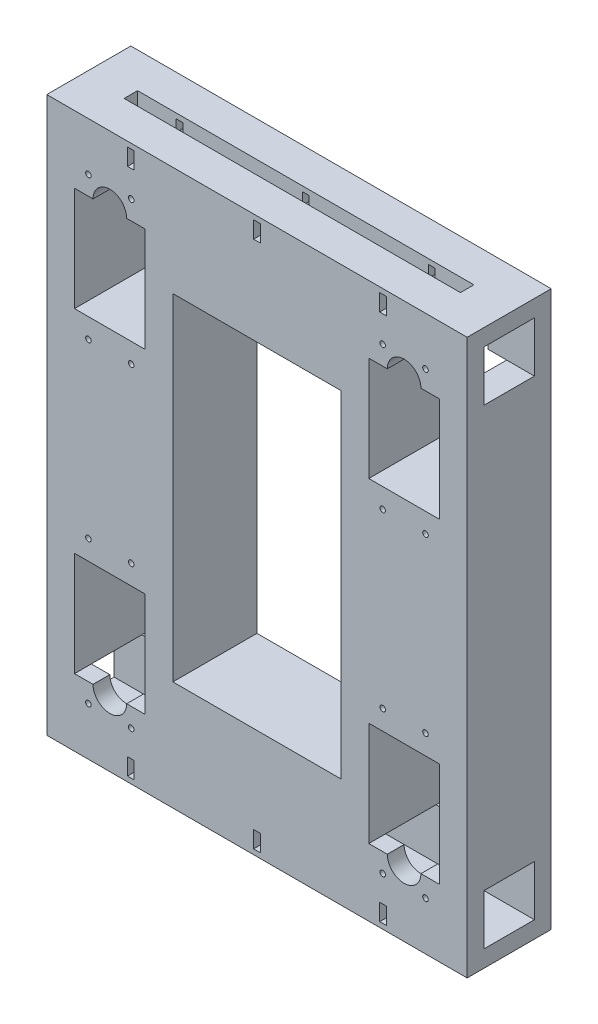
from build123d import *

# Parameters (mm, degrees)
CROQUIS1_W                                     = 250
CROQUIS1_H                                     = 250
CROQUIS1_W_2                                   = 100
CROQUIS1_H_2                                   = 200
SALIENTE_EXTRUIR1_DEPTH                        = 50
SALIENTE_EXTRUIR2_DEPTH                        = 250
CROQUIS5_W                                     = 200
CROQUIS5_H                                     = 8
CORTAR_EXTRUIR1_DEPTH                          = 10
CORTAR_EXTRUIR3_DEPTH                          = 51
CORTAR_EXTRUIR5_DEPTH                          = 51
PERFORADOR_PARA_ROSCAR_PARA_MACHO_DE_2_COUNT   = 2
PERFORADOR_PARA_ROSCAR_PARA_MACHO_DE_2_PITCH   = 25.455844123
PERFORADOR_PARA_ROSCAR_PARA_MACHO_DE_3_COUNT   = 2
PERFORADOR_PARA_ROSCAR_PARA_MACHO_DE_3_PITCH   = 88.729927308
PERFORADOR_PARA_ROSCAR_PARA_MACHO_DE_4_COUNT   = 2
PERFORADOR_PARA_ROSCAR_PARA_MACHO_DE_4_PITCH   = 85
PERFORADOR_PARA_ROSCAR_PARA_MACHO_DE_5_COUNT   = 2
PERFORADOR_PARA_ROSCAR_PARA_MACHO_DE_5_PITCH   = 175
PERFORADOR_PARA_ROSCAR_PARA_MACHO_DE_6_COUNT   = 2
PERFORADOR_PARA_ROSCAR_PARA_MACHO_DE_6_PITCH   = 149.544155877
PERFORADOR_PARA_ROSCAR_PARA_MACHO_DE_7_COUNT   = 2
PERFORADOR_PARA_ROSCAR_PARA_MACHO_DE_7_PITCH   = 194.550764583
PERFORADOR_PARA_ROSCAR_PARA_MACHO_DE_8_COUNT   = 2
PERFORADOR_PARA_ROSCAR_PARA_MACHO_DE_8_PITCH   = 172.012948806
PERFORADOR_PARA_ROSCAR_PARA_MACHO_DE_9_A_COUNT = 2
PERFORADOR_PARA_ROSCAR_PARA_MACHO_DE_9_A_PITCH = 25.455844123
PERFORADOR_PARA_ROSCAR_PARA_MACHO_DE_10_COUNT  = 2
PERFORADOR_PARA_ROSCAR_PARA_MACHO_DE_10_PITCH  = 88.729927308
PERFORADOR_PARA_ROSCAR_PARA_MACHO_DE_11_COUNT  = 2
PERFORADOR_PARA_ROSCAR_PARA_MACHO_DE_11_PITCH  = 85
PERFORADOR_PARA_ROSCAR_PARA_MACHO_DE_12_COUNT  = 2
PERFORADOR_PARA_ROSCAR_PARA_MACHO_DE_12_PITCH  = 194.550764583
PERFORADOR_PARA_ROSCAR_PARA_MACHO_DE_13_COUNT  = 2
PERFORADOR_PARA_ROSCAR_PARA_MACHO_DE_13_PITCH  = 172.012948806
PERFORADOR_PARA_ROSCAR_PARA_MACHO_DE_14_COUNT  = 2
PERFORADOR_PARA_ROSCAR_PARA_MACHO_DE_14_PITCH  = 149.544155877
PERFORADOR_PARA_ROSCAR_PARA_MACHO_DE_15_COUNT  = 2
PERFORADOR_PARA_ROSCAR_PARA_MACHO_DE_15_PITCH  = 175
SALIENTE_EXTRUIR4_DEPTH                        = 50
CROQUIS15_W                                    = 200
CROQUIS15_H                                    = 8
CORTAR_EXTRUIR6_DEPTH                          = 30
CROQUIS16_W                                    = 30
CROQUIS16_H                                    = 30
CORTAR_EXTRUIR7_DEPTH                          = 251
CROQUIS17_R                                    = 1.5
CORTAR_EXTRUIR8_DEPTH                          = 2
SIMETR_A6_COPY_1_SKETCH_R                      = 1.5
SIMETR_A6_COPY_1_DEPTH                         = 2


with BuildPart() as part:
    # Croquis1 → Saliente-Extruir1 (new body)
    with BuildSketch(Plane.XY):
        with Locations((125, 125)):
            Rectangle(CROQUIS1_W, CROQUIS1_H)
        with Locations((125, 125)):
            Rectangle(CROQUIS1_W_2, CROQUIS1_H_2, mode=Mode.SUBTRACT)
    extrude(amount=SALIENTE_EXTRUIR1_DEPTH)

    # Croquis4 → Saliente-Extruir2 (add, through all)
    with BuildSketch(Plane(origin=(250, 0, 0), x_dir=(0, 0, -1), z_dir=(1, 0, 0))):
        Polygon((-10, 280), (-10, 250), (0, 250), (0, 290), (-50, 290), (-50, 250), (-40, 250), (-40, 280), (-25, 280), align=None)
        Polygon((0, 0), (0, -40), (-50, -40), (-50, 0), (-40, 0), (-40, -30), (-25, -30), (-10, -30), (-10, 0), align=None)
    extrude(amount=-SALIENTE_EXTRUIR2_DEPTH)

    # Croquis5 → Cortar-Extruir1 (cut)
    with BuildSketch(Plane(origin=(0, 290, 0), x_dir=(1, 0, 0), z_dir=(0, 1, 0))):
        with Locations((125, -25)):
            Rectangle(CROQUIS5_W, CROQUIS5_H)
    cortar_extruir1 = extrude(amount=-CORTAR_EXTRUIR1_DEPTH, mode=Mode.SUBTRACT)

    # Croquis7 → Cortar-Extruir3 (cut, through all)
    with BuildSketch(Plane.XY.offset(50)):
        with BuildLine():
            Line((198, 287), (198, 277))
            ThreePointArc((198, 277), (200, 275), (202, 277))
            Line((202, 277), (202, 287))
            ThreePointArc((202, 287), (200, 289), (198, 287))
        make_face()
        with BuildLine():
            Line((127, 287), (127, 277))
            ThreePointArc((127, 277), (125, 275), (123, 277))
            Line((123, 277), (123, 287))
            ThreePointArc((123, 287), (125, 289), (127, 287))
        make_face()
        with BuildLine():
            Line((48, 287), (48, 277))
            ThreePointArc((48, 277), (50, 275), (52, 277))
            Line((52, 277), (52, 287))
            ThreePointArc((52, 287), (50, 289), (48, 287))
        make_face()
    cortar_extruir3 = extrude(amount=-CORTAR_EXTRUIR3_DEPTH, mode=Mode.SUBTRACT)

    # Croquis8 → Cortar-Extruir5 (cut, through all)
    with BuildSketch(Plane.XY.offset(50)):
        with BuildLine():
            Line((27.5, 250), (16.5, 250))
            Line((16.5, 250), (16.5, 188))
            Line((16.5, 188), (58.5, 188))
            Line((58.5, 188), (58.5, 250))
            Line((58.5, 250), (47.5, 250))
            ThreePointArc((47.5, 250), (37.5, 260), (27.5, 250))
        make_face()
        with BuildLine():
            Line((191.5, 250), (202.5, 250))
            ThreePointArc((202.5, 250), (212.5, 260), (222.5, 250))
            Line((222.5, 250), (233.5, 250))
            Line((233.5, 250), (233.5, 188))
            Line((233.5, 188), (191.5, 188))
            Line((191.5, 188), (191.5, 250))
        make_face()
    cortar_extruir5 = extrude(amount=-CORTAR_EXTRUIR5_DEPTH, mode=Mode.SUBTRACT)

    # Croquis11 → Perforador para roscar para macho de ros (revolve, cut)
    with BuildSketch(Plane(origin=(50.227922061, 261.272077939, 50), x_dir=(0, -1, 0), z_dir=(1, 0, 0))):
        Polygon((0, 0), (0, 10.991420021), (1.65, 10), (1.65, 0), align=None)
    perforador_para_roscar_para_macho_de_ros = revolve(axis=Axis((50.227922061, 261.272077939, 56.35), (0, 0, -1)), mode=Mode.SUBTRACT)

    # Perforador para roscar para macho de 2: Perforador para roscar para macho de ros ×2
    with Locations(*[(-i * PERFORADOR_PARA_ROSCAR_PARA_MACHO_DE_2_PITCH, 0, 0) for i in range(1, PERFORADOR_PARA_ROSCAR_PARA_MACHO_DE_2_COUNT)]):
        add(perforador_para_roscar_para_macho_de_ros, mode=Mode.SUBTRACT)

    # Perforador para roscar para macho de 3: Perforador para roscar para macho de ros ×2
    with Locations(*[Vector(-0.286891299, -0.957963143, 0) * (i * PERFORADOR_PARA_ROSCAR_PARA_MACHO_DE_3_PITCH) for i in range(1, PERFORADOR_PARA_ROSCAR_PARA_MACHO_DE_3_COUNT)]):
        add(perforador_para_roscar_para_macho_de_ros, mode=Mode.SUBTRACT)

    # Perforador para roscar para macho de 4: Perforador para roscar para macho de ros ×2
    with Locations(*[(0, -i * PERFORADOR_PARA_ROSCAR_PARA_MACHO_DE_4_PITCH, 0) for i in range(1, PERFORADOR_PARA_ROSCAR_PARA_MACHO_DE_4_COUNT)]):
        add(perforador_para_roscar_para_macho_de_ros, mode=Mode.SUBTRACT)

    # Perforador para roscar para macho de 5: Perforador para roscar para macho de ros ×2
    with Locations(*[(i * PERFORADOR_PARA_ROSCAR_PARA_MACHO_DE_5_PITCH, 0, 0) for i in range(1, PERFORADOR_PARA_ROSCAR_PARA_MACHO_DE_5_COUNT)]):
        add(perforador_para_roscar_para_macho_de_ros, mode=Mode.SUBTRACT)

    # Perforador para roscar para macho de 6: Perforador para roscar para macho de ros ×2
    with Locations(*[(i * PERFORADOR_PARA_ROSCAR_PARA_MACHO_DE_6_PITCH, 0, 0) for i in range(1, PERFORADOR_PARA_ROSCAR_PARA_MACHO_DE_6_COUNT)]):
        add(perforador_para_roscar_para_macho_de_ros, mode=Mode.SUBTRACT)

    # Perforador para roscar para macho de 7: Perforador para roscar para macho de ros ×2
    with Locations(*[Vector(0.899508159, -0.436903963, 0) * (i * PERFORADOR_PARA_ROSCAR_PARA_MACHO_DE_7_PITCH) for i in range(1, PERFORADOR_PARA_ROSCAR_PARA_MACHO_DE_7_COUNT)]):
        add(perforador_para_roscar_para_macho_de_ros, mode=Mode.SUBTRACT)

    # Perforador para roscar para macho de 8: Perforador para roscar para macho de ros ×2
    with Locations(*[Vector(0.869377317, -0.494148845, 0) * (i * PERFORADOR_PARA_ROSCAR_PARA_MACHO_DE_8_PITCH) for i in range(1, PERFORADOR_PARA_ROSCAR_PARA_MACHO_DE_8_COUNT)]):
        add(perforador_para_roscar_para_macho_de_ros, mode=Mode.SUBTRACT)

    # Croquis13 → Perforador para roscar para macho de 9 (revolve, cut)
    with BuildSketch(Plane(origin=(50.227922061, 261.272077939, 0), x_dir=(0, 1, 0), z_dir=(1, 0, 0))):
        Polygon((0, 0), (0, 10.991420021), (1.65, 10), (1.65, 0), align=None)
    perforador_para_roscar_para_macho_de_9 = revolve(axis=Axis((50.227922061, 261.272077939, -6.35), (0, 0, 1)), mode=Mode.SUBTRACT)

    # Perforador para roscar para macho de 9 a: Perforador para roscar para macho de 9 ×2
    with Locations(*[(-i * PERFORADOR_PARA_ROSCAR_PARA_MACHO_DE_9_A_PITCH, 0, 0) for i in range(1, PERFORADOR_PARA_ROSCAR_PARA_MACHO_DE_9_A_COUNT)]):
        add(perforador_para_roscar_para_macho_de_9, mode=Mode.SUBTRACT)

    # Perforador para roscar para macho de 10: Perforador para roscar para macho de 9 ×2
    with Locations(*[Vector(-0.286891299, -0.957963143, 0) * (i * PERFORADOR_PARA_ROSCAR_PARA_MACHO_DE_10_PITCH) for i in range(1, PERFORADOR_PARA_ROSCAR_PARA_MACHO_DE_10_COUNT)]):
        add(perforador_para_roscar_para_macho_de_9, mode=Mode.SUBTRACT)

    # Perforador para roscar para macho de 11: Perforador para roscar para macho de 9 ×2
    with Locations(*[(0, -i * PERFORADOR_PARA_ROSCAR_PARA_MACHO_DE_11_PITCH, 0) for i in range(1, PERFORADOR_PARA_ROSCAR_PARA_MACHO_DE_11_COUNT)]):
        add(perforador_para_roscar_para_macho_de_9, mode=Mode.SUBTRACT)

    # Perforador para roscar para macho de 12: Perforador para roscar para macho de 9 ×2
    with Locations(*[Vector(0.899508159, -0.436903963, 0) * (i * PERFORADOR_PARA_ROSCAR_PARA_MACHO_DE_12_PITCH) for i in range(1, PERFORADOR_PARA_ROSCAR_PARA_MACHO_DE_12_COUNT)]):
        add(perforador_para_roscar_para_macho_de_9, mode=Mode.SUBTRACT)

    # Perforador para roscar para macho de 13: Perforador para roscar para macho de 9 ×2
    with Locations(*[Vector(0.869377317, -0.494148845, 0) * (i * PERFORADOR_PARA_ROSCAR_PARA_MACHO_DE_13_PITCH) for i in range(1, PERFORADOR_PARA_ROSCAR_PARA_MACHO_DE_13_COUNT)]):
        add(perforador_para_roscar_para_macho_de_9, mode=Mode.SUBTRACT)

    # Perforador para roscar para macho de 14: Perforador para roscar para macho de 9 ×2
    with Locations(*[(i * PERFORADOR_PARA_ROSCAR_PARA_MACHO_DE_14_PITCH, 0, 0) for i in range(1, PERFORADOR_PARA_ROSCAR_PARA_MACHO_DE_14_COUNT)]):
        add(perforador_para_roscar_para_macho_de_9, mode=Mode.SUBTRACT)

    # Perforador para roscar para macho de 15: Perforador para roscar para macho de 9 ×2
    with Locations(*[(i * PERFORADOR_PARA_ROSCAR_PARA_MACHO_DE_15_PITCH, 0, 0) for i in range(1, PERFORADOR_PARA_ROSCAR_PARA_MACHO_DE_15_COUNT)]):
        add(perforador_para_roscar_para_macho_de_9, mode=Mode.SUBTRACT)

    # Simetría1: Cortar-Extruir1, Cortar-Extruir3, Cortar-Extruir5, Perforador para roscar para macho de ros, Perforador para roscar para macho de 9 across plane
    add(cortar_extruir1.mirror(Plane.ZX.offset(125)), mode=Mode.SUBTRACT)
    add(cortar_extruir3.mirror(Plane.ZX.offset(125)), mode=Mode.SUBTRACT)
    add(cortar_extruir5.mirror(Plane.ZX.offset(125)), mode=Mode.SUBTRACT)
    add(perforador_para_roscar_para_macho_de_ros.mirror(Plane.ZX.offset(125)), mode=Mode.SUBTRACT)
    add(perforador_para_roscar_para_macho_de_9.mirror(Plane.ZX.offset(125)), mode=Mode.SUBTRACT)

    # Simetría1 copy 1 sketch → Simetría1 copy 1 (revolve, cut)
    with BuildSketch(Plane(origin=(24.772077939, -11.272077939, 50), x_dir=(0, 1, 0), z_dir=(1, 0, 0))):
        Polygon((0, 0), (0, -10.991420021), (1.65, -10), (1.65, 0), align=None)
    revolve(axis=Axis((24.772077939, -11.272077939, 56.35), (0, 0, 1)), mode=Mode.SUBTRACT)

    # Simetría1 copy 2 sketch → Simetría1 copy 2 (revolve, cut)
    with BuildSketch(Plane(origin=(24.772077939, 73.727922061, 50), x_dir=(0, 1, 0), z_dir=(1, 0, 0))):
        Polygon((0, 0), (0, -10.991420021), (1.65, -10), (1.65, 0), align=None)
    revolve(axis=Axis((24.772077939, 73.727922061, 56.35), (0, 0, 1)), mode=Mode.SUBTRACT)

    # Simetría1 copy 3 sketch → Simetría1 copy 3 (revolve, cut)
    with BuildSketch(Plane(origin=(50.227922061, 73.727922061, 50), x_dir=(0, 1, 0), z_dir=(1, 0, 0))):
        Polygon((0, 0), (0, -10.991420021), (1.65, -10), (1.65, 0), align=None)
    revolve(axis=Axis((50.227922061, 73.727922061, 56.35), (0, 0, 1)), mode=Mode.SUBTRACT)

    # Simetría1 copy 4 sketch → Simetría1 copy 4 (revolve, cut)
    with BuildSketch(Plane(origin=(225.227922061, -11.272077939, 50), x_dir=(0, 1, 0), z_dir=(1, 0, 0))):
        Polygon((0, 0), (0, -10.991420021), (1.65, -10), (1.65, 0), align=None)
    revolve(axis=Axis((225.227922061, -11.272077939, 56.35), (0, 0, 1)), mode=Mode.SUBTRACT)

    # Simetría1 copy 5 sketch → Simetría1 copy 5 (revolve, cut)
    with BuildSketch(Plane(origin=(199.772077939, -11.272077939, 50), x_dir=(0, 1, 0), z_dir=(1, 0, 0))):
        Polygon((0, 0), (0, -10.991420021), (1.65, -10), (1.65, 0), align=None)
    revolve(axis=Axis((199.772077939, -11.272077939, 56.35), (0, 0, 1)), mode=Mode.SUBTRACT)

    # Simetría1 copy 6 sketch → Simetría1 copy 6 (revolve, cut)
    with BuildSketch(Plane(origin=(225.227922061, 73.727922061, 50), x_dir=(0, 1, 0), z_dir=(1, 0, 0))):
        Polygon((0, 0), (0, -10.991420021), (1.65, -10), (1.65, 0), align=None)
    revolve(axis=Axis((225.227922061, 73.727922061, 56.35), (0, 0, 1)), mode=Mode.SUBTRACT)

    # Simetría1 copy 7 sketch → Simetría1 copy 7 (revolve, cut)
    with BuildSketch(Plane(origin=(199.772077939, 73.727922061, 50), x_dir=(0, 1, 0), z_dir=(1, 0, 0))):
        Polygon((0, 0), (0, -10.991420021), (1.65, -10), (1.65, 0), align=None)
    revolve(axis=Axis((199.772077939, 73.727922061, 56.35), (0, 0, 1)), mode=Mode.SUBTRACT)

    # Simetría1 copy 8 sketch → Simetría1 copy 8 (revolve, cut)
    with BuildSketch(Plane(origin=(24.772077939, -11.272077939, 0), x_dir=(0, -1, 0), z_dir=(1, 0, 0))):
        Polygon((0, 0), (0, -10.991420021), (1.65, -10), (1.65, 0), align=None)
    revolve(axis=Axis((24.772077939, -11.272077939, -6.35), (0, 0, -1)), mode=Mode.SUBTRACT)

    # Simetría1 copy 9 sketch → Simetría1 copy 9 (revolve, cut)
    with BuildSketch(Plane(origin=(24.772077939, 73.727922061, 0), x_dir=(0, -1, 0), z_dir=(1, 0, 0))):
        Polygon((0, 0), (0, -10.991420021), (1.65, -10), (1.65, 0), align=None)
    revolve(axis=Axis((24.772077939, 73.727922061, -6.35), (0, 0, -1)), mode=Mode.SUBTRACT)

    # Simetría1 copy 10 sketch → Simetría1 copy 10 (revolve, cut)
    with BuildSketch(Plane(origin=(50.227922061, 73.727922061, 0), x_dir=(0, -1, 0), z_dir=(1, 0, 0))):
        Polygon((0, 0), (0, -10.991420021), (1.65, -10), (1.65, 0), align=None)
    revolve(axis=Axis((50.227922061, 73.727922061, -6.35), (0, 0, -1)), mode=Mode.SUBTRACT)

    # Simetría1 copy 11 sketch → Simetría1 copy 11 (revolve, cut)
    with BuildSketch(Plane(origin=(225.227922061, 73.727922061, 0), x_dir=(0, -1, 0), z_dir=(1, 0, 0))):
        Polygon((0, 0), (0, -10.991420021), (1.65, -10), (1.65, 0), align=None)
    revolve(axis=Axis((225.227922061, 73.727922061, -6.35), (0, 0, -1)), mode=Mode.SUBTRACT)

    # Simetría1 copy 12 sketch → Simetría1 copy 12 (revolve, cut)
    with BuildSketch(Plane(origin=(199.772077939, 73.727922061, 0), x_dir=(0, -1, 0), z_dir=(1, 0, 0))):
        Polygon((0, 0), (0, -10.991420021), (1.65, -10), (1.65, 0), align=None)
    revolve(axis=Axis((199.772077939, 73.727922061, -6.35), (0, 0, -1)), mode=Mode.SUBTRACT)

    # Simetría1 copy 13 sketch → Simetría1 copy 13 (revolve, cut)
    with BuildSketch(Plane(origin=(199.772077939, -11.272077939, 0), x_dir=(0, -1, 0), z_dir=(1, 0, 0))):
        Polygon((0, 0), (0, -10.991420021), (1.65, -10), (1.65, 0), align=None)
    revolve(axis=Axis((199.772077939, -11.272077939, -6.35), (0, 0, -1)), mode=Mode.SUBTRACT)

    # Simetría1 copy 14 sketch → Simetría1 copy 14 (revolve, cut)
    with BuildSketch(Plane(origin=(225.227922061, -11.272077939, 0), x_dir=(0, -1, 0), z_dir=(1, 0, 0))):
        Polygon((0, 0), (0, -10.991420021), (1.65, -10), (1.65, 0), align=None)
    revolve(axis=Axis((225.227922061, -11.272077939, -6.35), (0, 0, -1)), mode=Mode.SUBTRACT)

    # Croquis14 → Saliente-Extruir4 (add, through all)
    with BuildSketch(Plane(origin=(0, 0, 0), x_dir=(-1, 0, 0), z_dir=(0, 0, -1))):
        with BuildLine():
            Line((-202, 287), (-198, 287))
            ThreePointArc((-198, 287), (-200, 289), (-202, 287))
        make_face()
        with BuildLine():
            Line((-202, 277), (-198, 277))
            ThreePointArc((-198, 277), (-200, 275), (-202, 277))
        make_face()
        with BuildLine():
            Line((-127, 287), (-123, 287))
            ThreePointArc((-123, 287), (-125, 289), (-127, 287))
        make_face()
        with BuildLine():
            Line((-127, 277), (-123, 277))
            ThreePointArc((-123, 277), (-125, 275), (-127, 277))
        make_face()
        with BuildLine():
            Line((-52, 287), (-48, 287))
            ThreePointArc((-48, 287), (-50, 289), (-52, 287))
        make_face()
        with BuildLine():
            Line((-52, 277), (-48, 277))
            ThreePointArc((-48, 277), (-50, 275), (-52, 277))
        make_face()
    saliente_extruir4 = extrude(amount=-SALIENTE_EXTRUIR4_DEPTH)

    # Croquis15 → Cortar-Extruir6 (cut)
    with BuildSketch(Plane(origin=(0, 290, 0), x_dir=(1, 0, 0), z_dir=(0, 1, 0))):
        with Locations((125, -25)):
            Rectangle(CROQUIS15_W, CROQUIS15_H)
    cortar_extruir6 = extrude(amount=-CORTAR_EXTRUIR6_DEPTH, mode=Mode.SUBTRACT)

    # Croquis16 → Cortar-Extruir7 (cut, through all)
    with BuildSketch(Plane(origin=(250, 0, 0), x_dir=(0, 0, -1), z_dir=(1, 0, 0))):
        with Locations((-25, 265)):
            Rectangle(CROQUIS16_W, CROQUIS16_H)
    cortar_extruir7 = extrude(amount=-CORTAR_EXTRUIR7_DEPTH, mode=Mode.SUBTRACT)

    # Simetría4: Saliente-Extruir4, Cortar-Extruir6, Cortar-Extruir7 across plane
    add(saliente_extruir4.mirror(Plane.ZX.offset(125)))
    add(cortar_extruir6.mirror(Plane.ZX.offset(125)), mode=Mode.SUBTRACT)
    add(cortar_extruir7.mirror(Plane.ZX.offset(125)), mode=Mode.SUBTRACT)

    # Croquis17 → Cortar-Extruir8 (cut)
    with BuildSketch(Plane(origin=(0, 277, 0), x_dir=(1, 0, 0), z_dir=(0, 1, 0))):
        with Locations((50, -45)):
            Circle(CROQUIS17_R)
        with Locations((125, -45)):
            Circle(CROQUIS17_R)
        with Locations((200, -45)):
            Circle(CROQUIS17_R)
        with Locations((50, -5)):
            Circle(CROQUIS17_R)
        with Locations((125, -5)):
            Circle(CROQUIS17_R)
        with Locations((200, -5)):
            Circle(CROQUIS17_R)
    cortar_extruir8 = extrude(amount=-CORTAR_EXTRUIR8_DEPTH, mode=Mode.SUBTRACT)

    # Simetría5: Cortar-Extruir8 across plane
    add(cortar_extruir8.mirror(Plane.ZX.offset(282)), mode=Mode.SUBTRACT)

    # Simetría6: Cortar-Extruir8 across plane
    add(cortar_extruir8.mirror(Plane.ZX.offset(125)), mode=Mode.SUBTRACT)

    # Simetría6 copy 1 sketch → Simetría6 copy 1 (cut)
    with BuildSketch(Plane(origin=(0, -37, 0), x_dir=(1, 0, 0), z_dir=(0, 1, 0))):
        with Locations((50, -45)):
            Circle(SIMETR_A6_COPY_1_SKETCH_R)
        with Locations((125, -45)):
            Circle(SIMETR_A6_COPY_1_SKETCH_R)
        with Locations((200, -45)):
            Circle(SIMETR_A6_COPY_1_SKETCH_R)
        with Locations((50, -5)):
            Circle(SIMETR_A6_COPY_1_SKETCH_R)
        with Locations((125, -5)):
            Circle(SIMETR_A6_COPY_1_SKETCH_R)
        with Locations((200, -5)):
            Circle(SIMETR_A6_COPY_1_SKETCH_R)
    extrude(amount=-SIMETR_A6_COPY_1_DEPTH, mode=Mode.SUBTRACT)


solid = part.part
